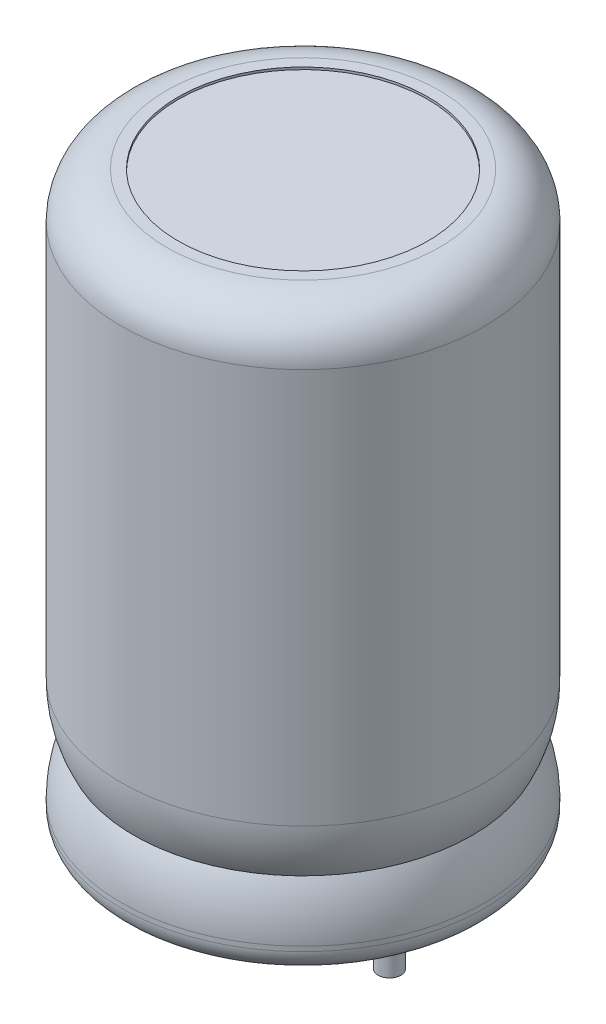
from build123d import *

# Parameters (mm, degrees)
SKETCH2_R           = 0.5
BOSS_EXTRUDE1_DEPTH = 3.5


with BuildPart() as part:
    # Sketch1 → Base-Revolve (revolve)
    with BuildSketch(Plane.XY):
        with BuildLine():
            Line((-3.81, 0.1), (1.69, 0.1))
            Line((1.69, 0.1), (1.69, 0))
            Line((1.69, 0), (3.19, 0))
            ThreePointArc((3.19, 0), (3.897106781, 0.292893219), (4.19, 1))
            Line((4.19, 1), (4.19, 1.21))
            ThreePointArc((4.19, 1.21), (4.049208002, 2.388175538), (3.634760961, 3.5))
            ThreePointArc((3.634760961, 3.5), (4.049208002, 4.611824462), (4.19, 5.79))
            Line((4.19, 5.79), (4.19, 23.2))
            ThreePointArc((4.19, 23.2), (3.604213562, 24.614213562), (2.19, 25.2))
            Line((2.19, 25.2), (1.69, 25.2))
            Line((1.69, 25.2), (1.69, 25.1))
            Line((1.69, 25.1), (-3.81, 25.1))
            Line((-3.81, 25.1), (-3.81, 0.1))
        make_face()
    revolve(axis=Axis((-3.81, 25.2, 0), (0, -1, 0)))

    # Sketch2 → Boss-Extrude1 (add)
    with BuildSketch(Plane.XZ.offset(-0.1)):
        Circle(SKETCH2_R)
        with Locations((-7.62, 0)):
            Circle(SKETCH2_R)
    extrude(amount=BOSS_EXTRUDE1_DEPTH)


solid = part.part
